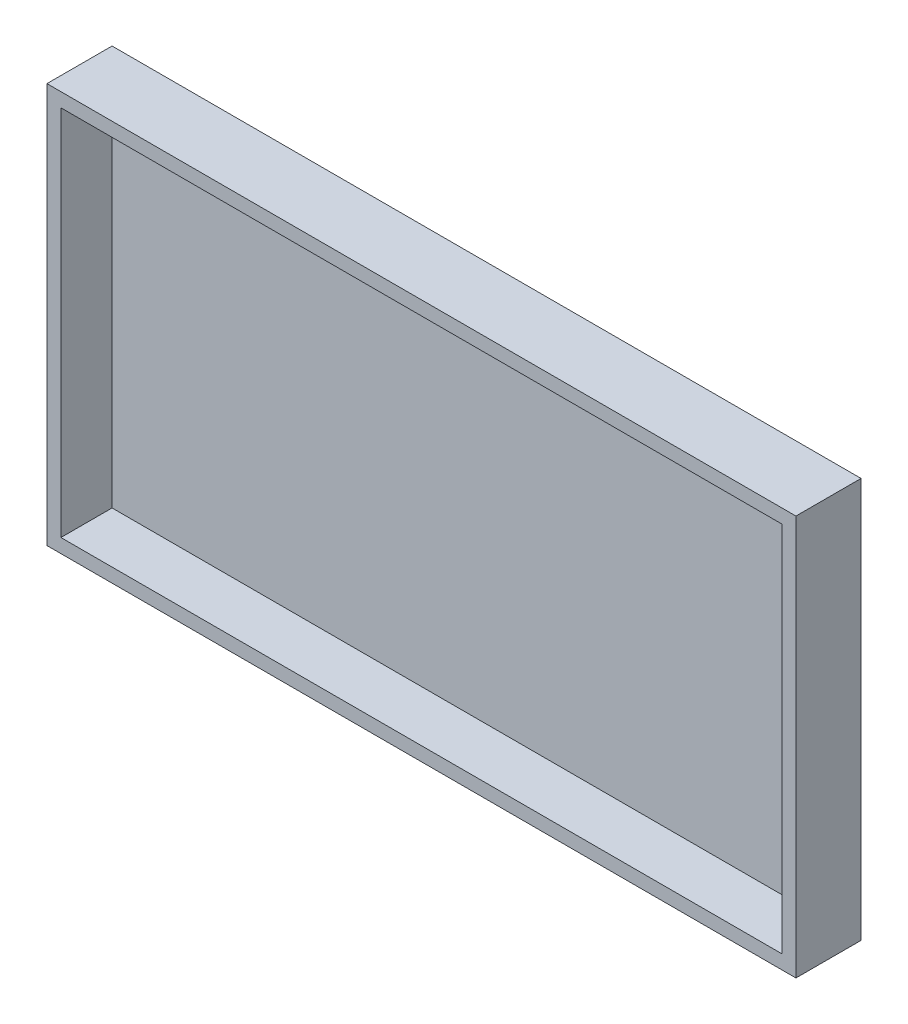
from build123d import *

# Parameters (mm, degrees)
SKETCH_1_W          = 161
SKETCH_1_H          = 86
EXTRUDE_2_DEPTH     = 14
SKETCH_2_W          = 155
SKETCH_2_H          = 80
CUT_EXTRUDE_1_DEPTH = 11


with BuildPart() as part:
    # 草圖1 → 填料-伸長2 (new body)
    with BuildSketch(Plane.XY):
        with Locations((20.723123278, -18.112244898)):
            Rectangle(SKETCH_1_W, SKETCH_1_H)
    extrude(amount=EXTRUDE_2_DEPTH)

    # 草圖2 → 除料-伸長1 (cut)
    with BuildSketch(Plane.XY.offset(14)):
        with Locations((20.723123278, -18.112244898)):
            Rectangle(SKETCH_2_W, SKETCH_2_H)
    extrude(amount=-CUT_EXTRUDE_1_DEPTH, mode=Mode.SUBTRACT)


solid = part.part
